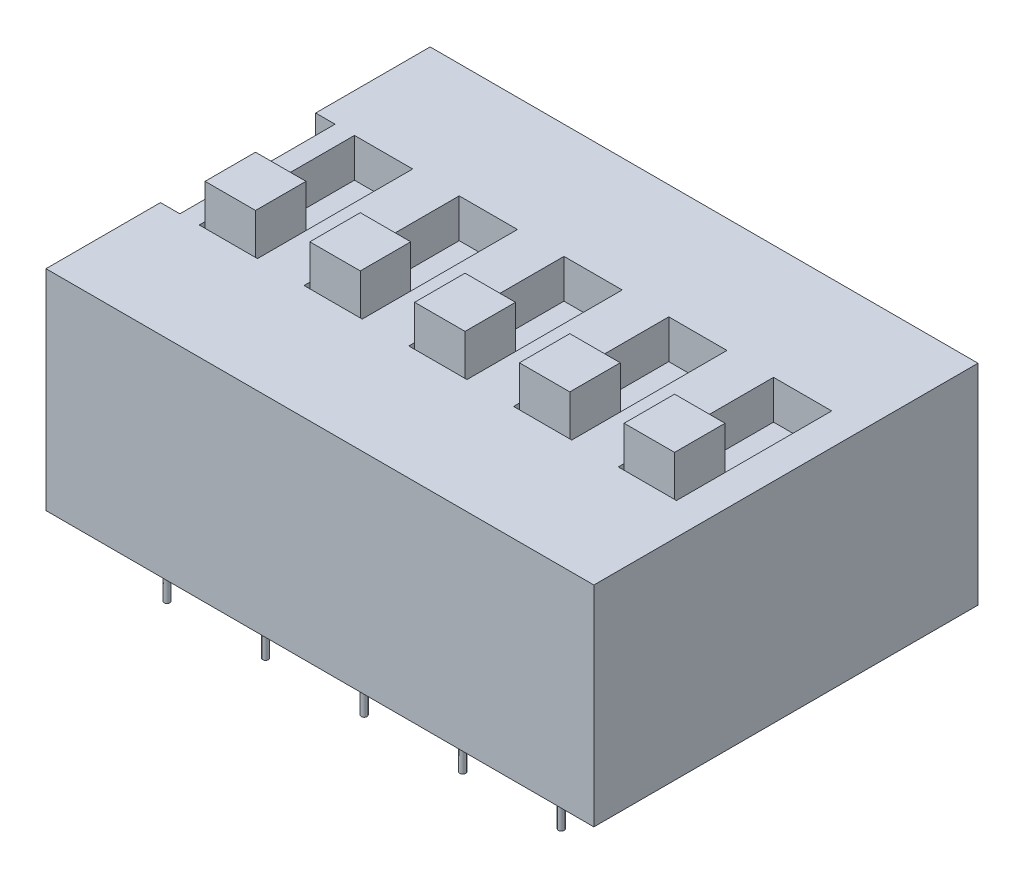
from build123d import *

# Parameters (mm, degrees)
SKETCH_1_W          = 14.12
SKETCH_1_H          = 9.9
EXTRUDE_1_DEPTH     = 5.4
SKETCH_2_R          = 0.075
EXTRUDE_2_DEPTH     = 1.6
SKETCH_3_W          = 0.5
SKETCH_3_H          = 4
CUT_EXTRUDE_1_DEPTH = 4
SKETCH_4_W          = 1.5
SKETCH_4_H          = 4
CUT_EXTRUDE_2_DEPTH = 1
SKETCH_5_W          = 1.3
SKETCH_5_H          = 1.3
EXTRUDE_3_DEPTH     = 2


with BuildPart() as part:
    # 草图1 → 凸台-拉伸1 (new body)
    with BuildSketch(Plane(origin=(0, 0, 0), x_dir=(1, 0, 0), z_dir=(0, 1, 0))):
        with Locations((7.06, 4.95)):
            Rectangle(SKETCH_1_W, SKETCH_1_H)
    extrude(amount=EXTRUDE_1_DEPTH)

    # 草图2 → 凸台-拉伸2 (add)
    with BuildSketch(Plane.XZ):
        with Locations((1.98, -1.14)):
            Circle(SKETCH_2_R)
        with Locations((4.52, -1.14)):
            Circle(SKETCH_2_R)
        with Locations((7.06, -1.14)):
            Circle(SKETCH_2_R)
        with Locations((9.6, -1.14)):
            Circle(SKETCH_2_R)
        with Locations((12.14, -1.14)):
            Circle(SKETCH_2_R)
        with Locations((4.52, -8.76)):
            Circle(SKETCH_2_R)
        with Locations((7.06, -8.76)):
            Circle(SKETCH_2_R)
        with Locations((9.6, -8.76)):
            Circle(SKETCH_2_R)
        with Locations((12.14, -8.76)):
            Circle(SKETCH_2_R)
        with Locations((1.98, -8.76)):
            Circle(SKETCH_2_R)
    extrude(amount=EXTRUDE_2_DEPTH)

    # 草图3 → 切除-拉伸1 (cut)
    with BuildSketch(Plane(origin=(0, 5.4, 0), x_dir=(1, 0, 0), z_dir=(0, 1, 0))):
        with Locations((0.25, 4.95)):
            Rectangle(SKETCH_3_W, SKETCH_3_H)
    extrude(amount=-CUT_EXTRUDE_1_DEPTH, mode=Mode.SUBTRACT)

    # 草图4 → 切除-拉伸2 (cut)
    with BuildSketch(Plane(origin=(0, 5.4, 0), x_dir=(1, 0, 0), z_dir=(0, 1, 0))):
        with Locations((4.45, 4.95)):
            Rectangle(SKETCH_4_W, SKETCH_4_H)
        with Locations((1.75, 4.95)):
            Rectangle(SKETCH_4_W, SKETCH_4_H)
        with Locations((7.15, 4.95)):
            Rectangle(SKETCH_4_W, SKETCH_4_H)
        with Locations((9.85, 4.95)):
            Rectangle(SKETCH_4_W, SKETCH_4_H)
        with Locations((12.55, 4.95)):
            Rectangle(SKETCH_4_W, SKETCH_4_H)
    extrude(amount=-CUT_EXTRUDE_2_DEPTH, mode=Mode.SUBTRACT)

    # 草图5 → 凸台-拉伸3 (add)
    with BuildSketch(Plane(origin=(0, 4.4, 0), x_dir=(1, 0, 0), z_dir=(0, 1, 0))):
        with Locations((4.45, 3.65)):
            Rectangle(SKETCH_5_W, SKETCH_5_H)
        with Locations((1.75, 3.65)):
            Rectangle(SKETCH_5_W, SKETCH_5_H)
        with Locations((7.15, 3.65)):
            Rectangle(SKETCH_5_W, SKETCH_5_H)
        with Locations((9.85, 3.65)):
            Rectangle(SKETCH_5_W, SKETCH_5_H)
        with Locations((12.55, 3.65)):
            Rectangle(SKETCH_5_W, SKETCH_5_H)
    extrude(amount=EXTRUDE_3_DEPTH)


solid = part.part
